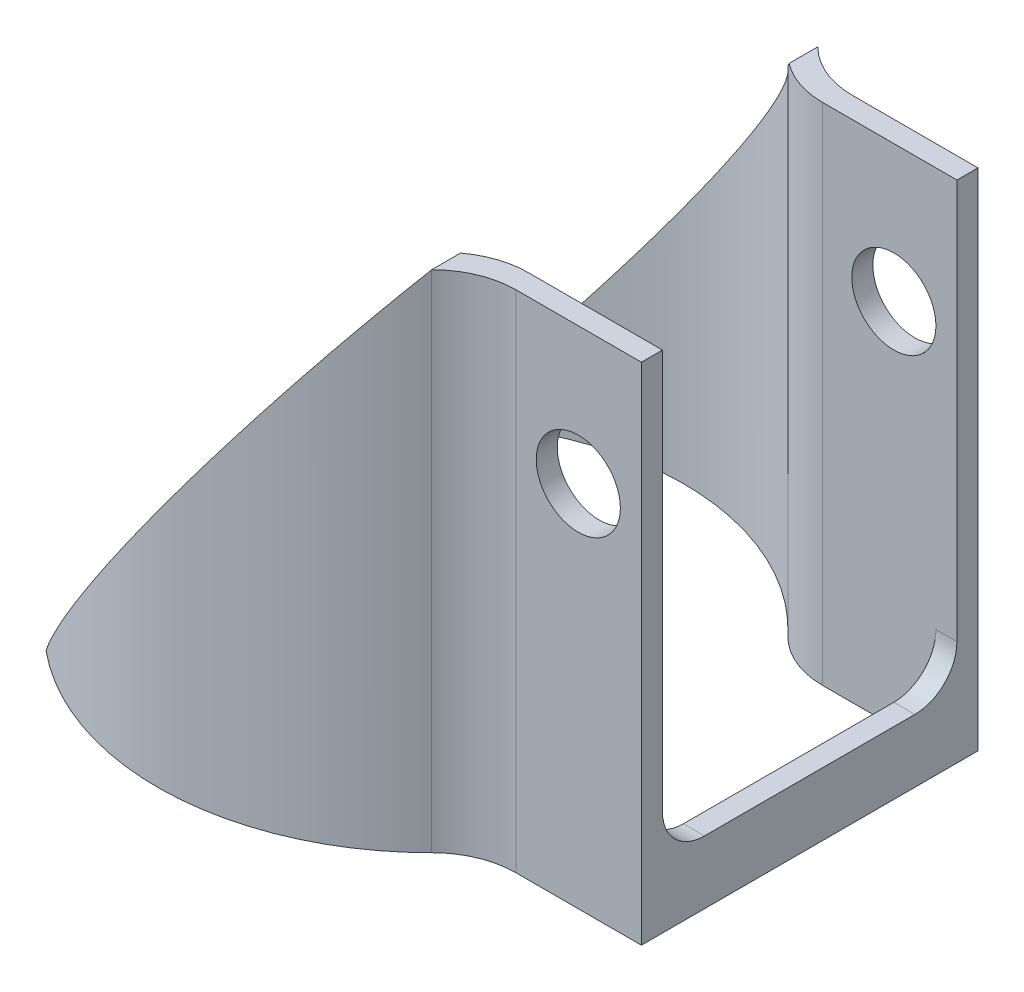
from build123d import *

# Parameters (mm, degrees)
BOSS_EXTRUDE1_DEPTH     = 24
FILLET1_R               = 4
CUT_EXTRUDE3_DEPTH      = 14
CUT_EXTRUDE3_DEPTH_BACK = 14
SKETCH5_R               = 2
CUT_EXTRUDE4_DEPTH      = 6
CUT_EXTRUDE4_DEPTH_BACK = 22
SKETCH7_W               = 14
SKETCH7_H               = 22.802557385
CUT_EXTRUDE5_DEPTH      = 1
CUT_EXTRUDE5_DEPTH_BACK = 27.278788925
FILLET2_R               = 2


with BuildPart() as part:
    # Sketch1 → Boss-Extrude1 (new body)
    with BuildSketch(Plane(origin=(0, 0, 0), x_dir=(1, 0, 0), z_dir=(0, 1, 0))):
        with BuildLine():
            Line((18, -8), (10.246950766, -8))
            ThreePointArc((10.246950766, -8), (-13, 0), (10.246950766, 8))
            Line((10.246950766, 8), (18, 8))
            Line((18, 8), (18, -8))
        make_face()
        with BuildLine():
            Line((17, -7), (9.746794345, -7))
            ThreePointArc((9.746794345, -7), (-12, 0), (9.746794345, 7))
            Line((9.746794345, 7), (17, 7))
            Line((17, 7), (17, -7))
        make_face(mode=Mode.SUBTRACT)
    extrude(amount=BOSS_EXTRUDE1_DEPTH)

    # Fillet1
    fillet1_edges = [part.edges().sort_by_distance(p)[0] for p in [
        (9.746794345, 12, -7),
        (9.746794345, 12, 7),
        (10.246950766, 12, 8),
        (10.246950766, 12, -8),
    ]]
    fillet(fillet1_edges, radius=FILLET1_R)

    # Sketch4 → Cut-Extrude3 (cut, two sides)
    with BuildSketch(Plane.XY) as cut_extrude3_sk:
        Polygon((-13, 0), (-8.278788925, 0), (9.208278207, 24), (-13, 24), align=None)
    extrude(amount=CUT_EXTRUDE3_DEPTH, mode=Mode.SUBTRACT)
    extrude(cut_extrude3_sk.sketch, amount=-CUT_EXTRUDE3_DEPTH_BACK, mode=Mode.SUBTRACT)

    # Sketch5 → Cut-Extrude4 (cut, two sides)
    with BuildSketch(Plane.XY.offset(8)) as cut_extrude4_sk:
        with Locations((15, 17.5)):
            Circle(SKETCH5_R)
    extrude(amount=CUT_EXTRUDE4_DEPTH, mode=Mode.SUBTRACT)
    extrude(cut_extrude4_sk.sketch, amount=-CUT_EXTRUDE4_DEPTH_BACK, mode=Mode.SUBTRACT)

    # Sketch7 → Cut-Extrude5 (cut, two sides)
    with BuildSketch(Plane(origin=(18, 0, 0), x_dir=(0, 0, -1), z_dir=(1, 0, 0))) as cut_extrude5_sk:
        with Locations((0, 14.401278693)):
            Rectangle(SKETCH7_W, SKETCH7_H)
    extrude(amount=CUT_EXTRUDE5_DEPTH, mode=Mode.SUBTRACT)
    extrude(cut_extrude5_sk.sketch, amount=-CUT_EXTRUDE5_DEPTH_BACK, mode=Mode.SUBTRACT)

    # Fillet2
    fillet2_edges = [part.edges().sort_by_distance(p)[0] for p in [
        (17.5, 3, -7),
        (17.5, 3, 7),
    ]]
    fillet(fillet2_edges, radius=FILLET2_R)


solid = part.part
